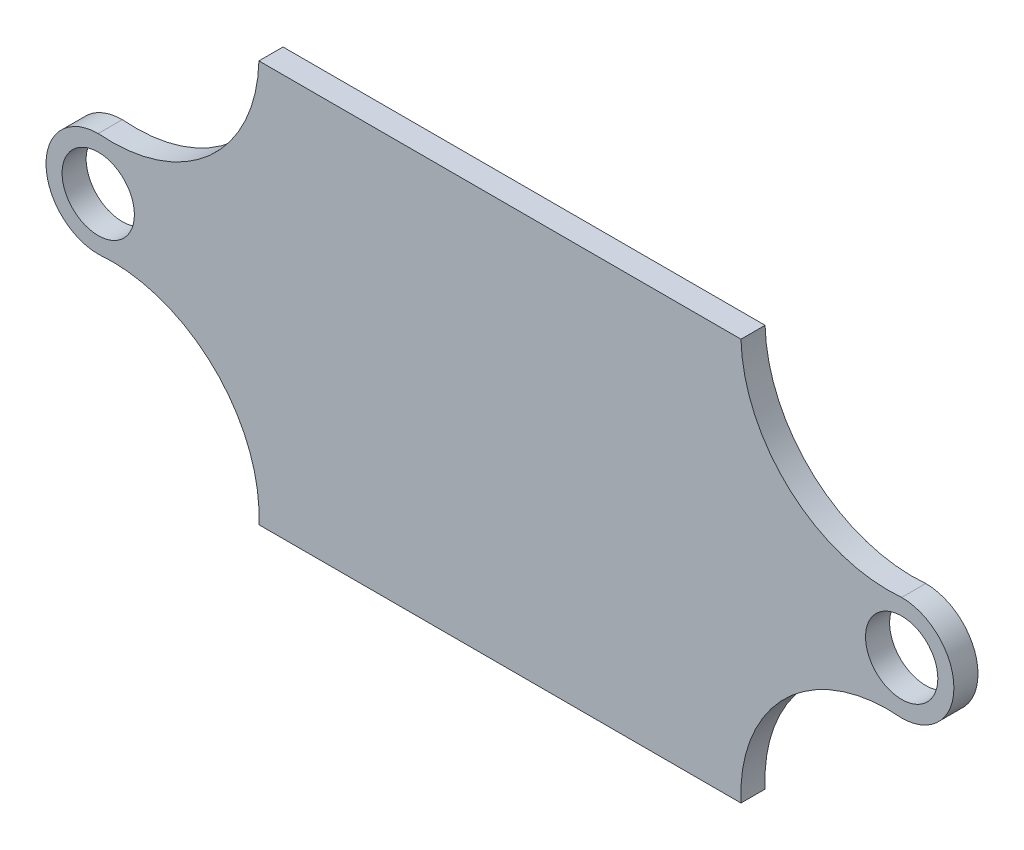
from build123d import *

# Parameters (mm, degrees)
SKETCH2_R           = 4.5
BOSS_EXTRUDE2_DEPTH = 3


with BuildPart() as part:
    # Sketch2 → Boss-Extrude2 (new body)
    with BuildSketch(Plane.XY):
        with BuildLine():
            ThreePointArc((-50, -5.834500909), (-56.5, 0.665499091), (-50, 7.165499091))
            ThreePointArc((-50, 7.165499091), (-36.130190824, 11.743060763), (-30, 25))
            Line((-30, 25), (30, 25))
            ThreePointArc((30, 25), (36.130190824, 11.743060763), (50, 7.165499091))
            ThreePointArc((50, 7.165499091), (56.5, 0.665499091), (50, -5.834500909))
            ThreePointArc((50, -5.834500909), (35.63018968, -10.857170595), (30, -25))
            Line((30, -25), (-30, -25))
            ThreePointArc((-30, -25), (-35.63018968, -10.857170595), (-50, -5.834500909))
        make_face()
        with Locations((50, 0.665499091)):
            Circle(SKETCH2_R, mode=Mode.SUBTRACT)
        with Locations((-50, 0.665499091)):
            Circle(SKETCH2_R, mode=Mode.SUBTRACT)
    extrude(amount=BOSS_EXTRUDE2_DEPTH)


solid = part.part
